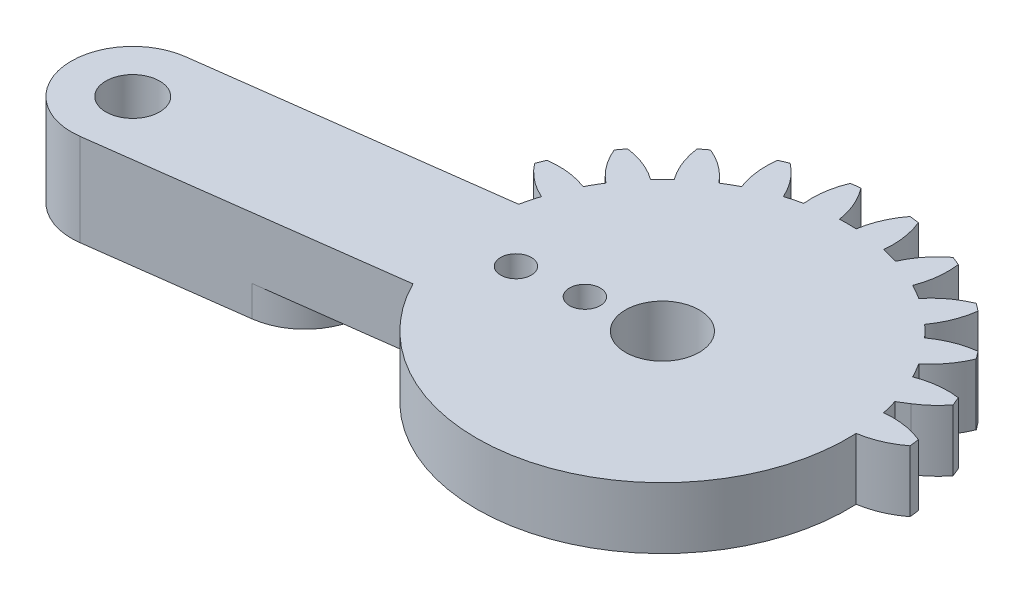
from build123d import *

# Parameters (mm, degrees)
SKETCH1_R           = 1.5
BOSS_EXTRUDE1_DEPTH = 4
SKETCH3_R           = 1.75
BOSS_EXTRUDE2_DEPTH = 4
CUT_EXTRUDE1_DEPTH  = 4
CUT_EXTRUDE2_REACH  = 6
SKETCH5_R           = 2.4
SKETCH5_R_2         = 1
SKETCH8_R           = 1.75
BOSS_EXTRUDE3_DEPTH = 2


with BuildPart() as part:
    # Sketch1 → Boss-Extrude1 (new body)
    with BuildSketch(Plane(origin=(0, 0, 0), x_dir=(1, 0, 0), z_dir=(0, 1, 0))):
        with BuildLine():
            Line((20.643657446, 4), (2.081641936, 4))
            ThreePointArc((2.081641936, 4), (2.861028333, 4.588201733), (3.521749436, 5.30713988))
            ThreePointArc((3.521749436, 5.30713988), (3.405395609, 5.596745198), (3.282888305, 5.883801663))
            ThreePointArc((3.282888305, 5.883801663), (1.93527598, 5.894040025), (0.627094961, 5.57027124))
            ThreePointArc((0.627094961, 5.57027124), (0.366286148, 6.046375), (0.084372603, 6.510293938))
            ThreePointArc((0.084372603, 6.510293938), (1.018855105, 7.48132754), (1.683794586, 8.65351323))
            ThreePointArc((1.683794586, 8.65351323), (1.496450048, 8.903135899), (1.303821399, 9.148703928))
            ThreePointArc((1.303821399, 9.148703928), (-0.000522033, 8.809805691), (-1.180330337, 8.158486898))
            ThreePointArc((-1.180330337, 8.158486898), (-1.555477026, 8.550865528), (-1.947855656, 8.926012217))
            ThreePointArc((-1.947855656, 8.926012217), (-1.296536862, 10.105820521), (-0.957638625, 11.410163953))
            ThreePointArc((-0.957638625, 11.410163953), (-1.203206655, 11.602792602), (-1.452829324, 11.79013714))
            ThreePointArc((-1.452829324, 11.79013714), (-2.625015014, 11.125197659), (-3.596048616, 10.190715157))
            ThreePointArc((-3.596048616, 10.190715157), (-4.059967554, 10.472628702), (-4.536071314, 10.733437515))
            ThreePointArc((-4.536071314, 10.733437515), (-4.212302529, 12.041618533), (-4.222540891, 13.389230859))
            ThreePointArc((-4.222540891, 13.389230859), (-4.509597355, 13.511738163), (-4.799202674, 13.62809199))
            ThreePointArc((-4.799202674, 13.62809199), (-5.759348103, 12.682425791), (-6.455432668, 11.528463019))
            ThreePointArc((-6.455432668, 11.528463019), (-6.976508546, 11.680699536), (-7.503891752, 11.809396783))
            ThreePointArc((-7.503891752, 11.809396783), (-7.529737283, 13.156800143), (-7.888414517, 14.455843809))
            ThreePointArc((-7.888414517, 14.455843809), (-8.197396993, 14.499881098), (-8.507248835, 14.537314892))
            ThreePointArc((-8.507248835, 14.537314892), (-9.18992168, 13.375367565), (-9.563620196, 12.080565177))
            ThreePointArc((-9.563620196, 12.080565177), (-10.106342554, 12.09275), (-10.649064912, 12.080565177))
            ThreePointArc((-10.649064912, 12.080565177), (-11.022763428, 13.375367565), (-11.705436272, 14.537314892))
            ThreePointArc((-11.705436272, 14.537314892), (-12.015288115, 14.499881098), (-12.324270591, 14.455843809))
            ThreePointArc((-12.324270591, 14.455843809), (-12.682947825, 13.156800143), (-12.708793355, 11.809396783))
            ThreePointArc((-12.708793355, 11.809396783), (-13.236176561, 11.680699536), (-13.757252439, 11.528463019))
            ThreePointArc((-13.757252439, 11.528463019), (-14.453337005, 12.682425791), (-15.413482434, 13.62809199))
            ThreePointArc((-15.413482434, 13.62809199), (-15.703087752, 13.511738163), (-15.990144217, 13.389230859))
            ThreePointArc((-15.990144217, 13.389230859), (-16.000382579, 12.041618533), (-15.676613793, 10.733437515))
            ThreePointArc((-15.676613793, 10.733437515), (-16.152717554, 10.472628702), (-16.616636492, 10.190715157))
            ThreePointArc((-16.616636492, 10.190715157), (-17.587670094, 11.125197659), (-18.759855783, 11.79013714))
            ThreePointArc((-18.759855783, 11.79013714), (-19.009478453, 11.602792602), (-19.255046482, 11.410163953))
            ThreePointArc((-19.255046482, 11.410163953), (-18.916148245, 10.105820521), (-18.264829452, 8.926012217))
            ThreePointArc((-18.264829452, 8.926012217), (-18.657208082, 8.550865528), (-19.032354771, 8.158486898))
            ThreePointArc((-19.032354771, 8.158486898), (-20.212163074, 8.809805691), (-21.516506507, 9.148703928))
            ThreePointArc((-21.516506507, 9.148703928), (-21.709135156, 8.903135899), (-21.896479694, 8.65351323))
            ThreePointArc((-21.896479694, 8.65351323), (-21.231540213, 7.48132754), (-20.297057711, 6.510293938))
            ThreePointArc((-20.297057711, 6.510293938), (-20.578971255, 6.046375), (-20.839780068, 5.57027124))
            ThreePointArc((-20.839780068, 5.57027124), (-22.147961087, 5.894040025), (-23.495573413, 5.883801663))
            ThreePointArc((-23.495573413, 5.883801663), (-23.618080717, 5.596745198), (-23.734434544, 5.30713988))
            ThreePointArc((-23.734434544, 5.30713988), (-22.788768345, 4.346994451), (-21.634805572, 3.650909885))
            ThreePointArc((-21.634805572, 3.650909885), (-21.78704209, 3.129834008), (-21.915739337, 2.602450802))
            ThreePointArc((-21.915739337, 2.602450802), (-23.263142697, 2.576605271), (-24.562186363, 2.217928037))
            ThreePointArc((-24.562186363, 2.217928037), (-24.606223651, 1.908945561), (-24.643657446, 1.599093719))
            ThreePointArc((-24.643657446, 1.599093719), (-23.481710119, 0.916420874), (-22.186907731, 0.542722358))
            ThreePointArc((-22.186907731, 0.542722358), (-22.199092554, 0), (-22.186907731, -0.542722358))
            ThreePointArc((-22.186907731, -0.542722358), (-23.481710119, -0.916420874), (-24.643657446, -1.599093719))
            ThreePointArc((-24.643657446, -1.599093719), (-24.606223651, -1.908945561), (-24.562186363, -2.217928037))
            ThreePointArc((-24.562186363, -2.217928037), (-23.263142697, -2.576605271), (-21.915739337, -2.602450802))
            ThreePointArc((-21.915739337, -2.602450802), (-21.78704209, -3.129834008), (-21.634805572, -3.650909885))
            ThreePointArc((-21.634805572, -3.650909885), (-22.788768345, -4.346994451), (-23.734434544, -5.30713988))
            ThreePointArc((-23.734434544, -5.30713988), (-23.618080717, -5.596745198), (-23.495573413, -5.883801663))
            ThreePointArc((-23.495573413, -5.883801663), (-22.147961087, -5.894040025), (-20.839780068, -5.57027124))
            ThreePointArc((-20.839780068, -5.57027124), (-20.578971255, -6.046375), (-20.297057711, -6.510293938))
            ThreePointArc((-20.297057711, -6.510293938), (-21.231540213, -7.48132754), (-21.896479694, -8.65351323))
            ThreePointArc((-21.896479694, -8.65351323), (-21.709135156, -8.903135899), (-21.516506507, -9.148703928))
            ThreePointArc((-21.516506507, -9.148703928), (-20.212163074, -8.809805691), (-19.032354771, -8.158486898))
            ThreePointArc((-19.032354771, -8.158486898), (-18.657208082, -8.550865528), (-18.264829452, -8.926012217))
            ThreePointArc((-18.264829452, -8.926012217), (-18.916148245, -10.105820521), (-19.255046482, -11.410163953))
            ThreePointArc((-19.255046482, -11.410163953), (-19.009478453, -11.602792602), (-18.759855783, -11.79013714))
            ThreePointArc((-18.759855783, -11.79013714), (-17.587670094, -11.125197659), (-16.616636492, -10.190715157))
            ThreePointArc((-16.616636492, -10.190715157), (-16.152717554, -10.472628702), (-15.676613793, -10.733437515))
            ThreePointArc((-15.676613793, -10.733437515), (-16.000382579, -12.041618533), (-15.990144217, -13.389230859))
            ThreePointArc((-15.990144217, -13.389230859), (-15.703087752, -13.511738163), (-15.413482434, -13.62809199))
            ThreePointArc((-15.413482434, -13.62809199), (-14.453337005, -12.682425791), (-13.757252439, -11.528463019))
            ThreePointArc((-13.757252439, -11.528463019), (-13.236176561, -11.680699536), (-12.708793355, -11.809396783))
            ThreePointArc((-12.708793355, -11.809396783), (-12.682947825, -13.156800143), (-12.324270591, -14.455843809))
            ThreePointArc((-12.324270591, -14.455843809), (-12.015288115, -14.499881098), (-11.705436272, -14.537314892))
            ThreePointArc((-11.705436272, -14.537314892), (-11.022763428, -13.375367565), (-10.649064912, -12.080565177))
            ThreePointArc((-10.649064912, -12.080565177), (-10.106342554, -12.09275), (-9.563620196, -12.080565177))
            ThreePointArc((-9.563620196, -12.080565177), (-9.18992168, -13.375367565), (-8.507248835, -14.537314892))
            ThreePointArc((-8.507248835, -14.537314892), (-8.197396993, -14.499881098), (-7.888414517, -14.455843809))
            ThreePointArc((-7.888414517, -14.455843809), (-7.529737283, -13.156800143), (-7.503891752, -11.809396783))
            ThreePointArc((-7.503891752, -11.809396783), (-6.976508546, -11.680699536), (-6.455432668, -11.528463019))
            ThreePointArc((-6.455432668, -11.528463019), (-5.759348103, -12.682425791), (-4.799202674, -13.62809199))
            ThreePointArc((-4.799202674, -13.62809199), (-4.509597355, -13.511738163), (-4.222540891, -13.389230859))
            ThreePointArc((-4.222540891, -13.389230859), (-4.212302529, -12.041618533), (-4.536071314, -10.733437515))
            ThreePointArc((-4.536071314, -10.733437515), (-4.059967554, -10.472628702), (-3.596048616, -10.190715157))
            ThreePointArc((-3.596048616, -10.190715157), (-2.625015014, -11.125197659), (-1.452829324, -11.79013714))
            ThreePointArc((-1.452829324, -11.79013714), (-1.203206655, -11.602792602), (-0.957638625, -11.410163953))
            ThreePointArc((-0.957638625, -11.410163953), (-1.296536862, -10.105820521), (-1.947855656, -8.926012217))
            ThreePointArc((-1.947855656, -8.926012217), (-1.555477026, -8.550865528), (-1.180330337, -8.158486898))
            ThreePointArc((-1.180330337, -8.158486898), (-0.000522033, -8.809805691), (1.303821399, -9.148703928))
            ThreePointArc((1.303821399, -9.148703928), (1.496450048, -8.903135899), (1.683794586, -8.65351323))
            ThreePointArc((1.683794586, -8.65351323), (1.018855105, -7.48132754), (0.084372603, -6.510293938))
            ThreePointArc((0.084372603, -6.510293938), (0.366286148, -6.046375), (0.627094961, -5.57027124))
            ThreePointArc((0.627094961, -5.57027124), (1.93527598, -5.894040025), (3.282888305, -5.883801663))
            ThreePointArc((3.282888305, -5.883801663), (3.405395609, -5.596745198), (3.521749436, -5.30713988))
            ThreePointArc((3.521749436, -5.30713988), (2.861028333, -4.588201733), (2.081641936, -4))
            Line((2.081641936, -4), (20.643657446, -4))
            ThreePointArc((20.643657446, -4), (24.643657446, 0), (20.643657446, 4))
        make_face()
        with Locations((-10.106342554, 0)):
            Circle(SKETCH1_R, mode=Mode.SUBTRACT)
        with Locations((20.643657446, 0)):
            Circle(SKETCH1_R, mode=Mode.SUBTRACT)
    extrude(amount=BOSS_EXTRUDE1_DEPTH)

    # Sketch3 → Boss-Extrude2 (add)
    with BuildSketch(Plane(origin=(0, 4, 0), x_dir=(1, 0, 0), z_dir=(0, 1, 0))):
        with BuildLine():
            ThreePointArc((-9.584237785, -3.965779445), (-14.072121999, -0.522104769), (-10.628447323, 3.965779445))
            Line((-10.628447323, 3.965779445), (-41.11537681, -0.047900965))
            ThreePointArc((-41.11537681, -0.047900965), (-44.559051487, -4.53578518), (-40.071167272, -7.979459856))
            Line((-40.071167272, -7.979459856), (-9.584237785, -3.965779445))
        make_face()
        with Locations((-40.593272041, -4.013680411)):
            Circle(SKETCH3_R, mode=Mode.SUBTRACT)
    extrude(amount=-BOSS_EXTRUDE2_DEPTH)

    # Sketch4 → Cut-Extrude1 (cut)
    with BuildSketch(Plane(origin=(0, 4, 0), x_dir=(1, 0, 0), z_dir=(0, 1, 0))):
        with BuildLine():
            ThreePointArc((20.643657446, -4), (24.643657446, 0), (20.643657446, 4))
            Line((20.643657446, 4), (2.081641936, 4))
            Line((2.081641936, 4), (1.43808022, 3.600125745))
            ThreePointArc((1.43808022, 3.600125745), (1.581217534, 3.104116905), (1.70305423, 2.602450802))
            ThreePointArc((1.70305423, 2.602450802), (3.050457589, 2.576605271), (4.349501255, 2.217928037))
            ThreePointArc((4.349501255, 2.217928037), (4.393538544, 1.908945561), (4.430972339, 1.599093719))
            ThreePointArc((4.430972339, 1.599093719), (3.269025011, 0.916420874), (1.974222624, 0.542722358))
            ThreePointArc((1.974222624, 0.542722358), (1.70305423, -2.602450802), (0.627094961, -5.57027124))
            ThreePointArc((0.627094961, -5.57027124), (1.93527598, -5.894040025), (3.282888305, -5.883801663))
            ThreePointArc((3.282888305, -5.883801663), (3.405395609, -5.596745198), (3.521749436, -5.30713988))
            ThreePointArc((3.521749436, -5.30713988), (2.861028333, -4.588201733), (2.081641936, -4))
            Line((2.081641936, -4), (20.643657446, -4))
        make_face()
        with BuildLine():
            ThreePointArc((1.683794586, -8.65351323), (1.018855105, -7.48132754), (0.084372603, -6.510293938))
            ThreePointArc((0.084372603, -6.510293938), (-0.512518948, -7.361599771), (-1.180330337, -8.158486898))
            ThreePointArc((-1.180330337, -8.158486898), (-0.000522033, -8.809805691), (1.303821399, -9.148703928))
            ThreePointArc((1.303821399, -9.148703928), (1.496450048, -8.903135899), (1.683794586, -8.65351323))
        make_face()
        with BuildLine():
            ThreePointArc((-0.957638625, -11.410163953), (-1.296536862, -10.105820521), (-1.947855656, -8.926012217))
            ThreePointArc((-1.947855656, -8.926012217), (-2.744742783, -9.593823606), (-3.596048616, -10.190715157))
            ThreePointArc((-3.596048616, -10.190715157), (-2.625015014, -11.125197659), (-1.452829324, -11.79013714))
            ThreePointArc((-1.452829324, -11.79013714), (-1.203206655, -11.602792602), (-0.957638625, -11.410163953))
        make_face()
        with BuildLine():
            ThreePointArc((-4.222540891, -13.389230859), (-4.212302529, -12.041618533), (-4.536071314, -10.733437515))
            ThreePointArc((-4.536071314, -10.733437515), (-5.478647477, -11.172244217), (-6.455432668, -11.528463019))
            ThreePointArc((-6.455432668, -11.528463019), (-5.759348103, -12.682425791), (-4.799202674, -13.62809199))
            ThreePointArc((-4.799202674, -13.62809199), (-4.509597355, -13.511738163), (-4.222540891, -13.389230859))
        make_face()
        with BuildLine():
            ThreePointArc((-7.888414517, -14.455843809), (-7.529737283, -13.156800143), (-7.503891752, -11.809396783))
            ThreePointArc((-7.503891752, -11.809396783), (-8.527921943, -11.989294847), (-9.563620196, -12.080565177))
            ThreePointArc((-9.563620196, -12.080565177), (-9.18992168, -13.375367565), (-8.507248835, -14.537314892))
            ThreePointArc((-8.507248835, -14.537314892), (-8.197396993, -14.499881098), (-7.888414517, -14.455843809))
        make_face()
        with BuildLine():
            ThreePointArc((-11.705436272, -14.537314892), (-11.022763428, -13.375367565), (-10.649064912, -12.080565177))
            ThreePointArc((-10.649064912, -12.080565177), (-11.684763165, -11.989294847), (-12.708793355, -11.809396783))
            ThreePointArc((-12.708793355, -11.809396783), (-12.682947825, -13.156800143), (-12.324270591, -14.455843809))
            ThreePointArc((-12.324270591, -14.455843809), (-12.015288115, -14.499881098), (-11.705436272, -14.537314892))
        make_face()
        with BuildLine():
            ThreePointArc((-15.413482434, -13.62809199), (-14.453337005, -12.682425791), (-13.757252439, -11.528463019))
            ThreePointArc((-13.757252439, -11.528463019), (-14.734037631, -11.172244217), (-15.676613793, -10.733437515))
            ThreePointArc((-15.676613793, -10.733437515), (-16.000382579, -12.041618533), (-15.990144217, -13.389230859))
            ThreePointArc((-15.990144217, -13.389230859), (-15.703087752, -13.511738163), (-15.413482434, -13.62809199))
        make_face()
        with BuildLine():
            ThreePointArc((-18.759855783, -11.79013714), (-17.587670094, -11.125197659), (-16.616636492, -10.190715157))
            ThreePointArc((-16.616636492, -10.190715157), (-17.467942324, -9.593823606), (-18.264829452, -8.926012217))
            ThreePointArc((-18.264829452, -8.926012217), (-18.916148245, -10.105820521), (-19.255046482, -11.410163953))
            ThreePointArc((-19.255046482, -11.410163953), (-19.009478453, -11.602792602), (-18.759855783, -11.79013714))
        make_face()
        with BuildLine():
            ThreePointArc((-21.516506507, -9.148703928), (-20.212163074, -8.809805691), (-19.032354771, -8.158486898))
            ThreePointArc((-19.032354771, -8.158486898), (-19.70016616, -7.361599771), (-20.297057711, -6.510293938))
            ThreePointArc((-20.297057711, -6.510293938), (-21.231540213, -7.48132754), (-21.896479694, -8.65351323))
            ThreePointArc((-21.896479694, -8.65351323), (-21.709135156, -8.903135899), (-21.516506507, -9.148703928))
        make_face()
        with BuildLine():
            ThreePointArc((-21.942853375, 2.47620963), (-21.92946485, 2.539366405), (-21.915739337, 2.602450802))
            ThreePointArc((-21.915739337, 2.602450802), (-23.263142697, 2.576605271), (-24.562186363, 2.217928037))
            ThreePointArc((-24.562186363, 2.217928037), (-24.56889027, 2.173784387), (-24.575459377, 2.129620475))
            Line((-24.575459377, 2.129620475), (-21.942853375, 2.47620963))
        make_face()
        with BuildLine():
            ThreePointArc((-23.495573413, -5.883801663), (-22.147961087, -5.894040025), (-20.839780068, -5.57027124))
            ThreePointArc((-20.839780068, -5.57027124), (-20.869365339, -5.512888815), (-20.898643838, -5.455349261))
            Line((-20.898643838, -5.455349261), (-23.531249839, -5.801938416))
            ThreePointArc((-23.531249839, -5.801938416), (-23.513474108, -5.842897269), (-23.495573413, -5.883801663))
        make_face()
    extrude(amount=-CUT_EXTRUDE1_DEPTH, mode=Mode.SUBTRACT)

    # Sketch5 → Cut-Extrude2 (cut, up to next)
    with BuildSketch(Plane(origin=(0, 4, 0), x_dir=(1, 0, 0), z_dir=(0, 1, 0)), mode=Mode.PRIVATE) as cut_extrude2_sk1:
        with Locations((-10.106342554, 0)):
            Circle(SKETCH5_R)
    cut_extrude2_tool1 = extrude(cut_extrude2_sk1.sketch, amount=-CUT_EXTRUDE2_REACH, mode=Mode.PRIVATE) & part.part
    add(cut_extrude2_tool1.solids().sort_by_distance((-10.106343, 4, 0))[0], mode=Mode.SUBTRACT)
    # Sketch5 → Cut-Extrude2 (cut, up to next)
    with BuildSketch(Plane(origin=(0, 4, 0), x_dir=(1, 0, 0), z_dir=(0, 1, 0)), mode=Mode.PRIVATE) as cut_extrude2_sk2:
        with Locations((-14.56784443, -0.587367865)):
            Circle(SKETCH5_R_2)
    cut_extrude2_tool2 = extrude(cut_extrude2_sk2.sketch, amount=-CUT_EXTRUDE2_REACH, mode=Mode.PRIVATE) & part.part
    add(cut_extrude2_tool2.solids().sort_by_distance((-14.567844, 4, 0.587368))[0], mode=Mode.SUBTRACT)
    # Sketch5 → Cut-Extrude2 (cut, up to next)
    with BuildSketch(Plane(origin=(0, 4, 0), x_dir=(1, 0, 0), z_dir=(0, 1, 0)), mode=Mode.PRIVATE) as cut_extrude2_sk3:
        with Locations((-18.533623876, -1.109472634)):
            Circle(SKETCH5_R_2)
    cut_extrude2_tool3 = extrude(cut_extrude2_sk3.sketch, amount=-CUT_EXTRUDE2_REACH, mode=Mode.PRIVATE) & part.part
    add(cut_extrude2_tool3.solids().sort_by_distance((-18.533624, 4, 1.109473))[0], mode=Mode.SUBTRACT)

    # Sketch8 → Boss-Extrude3 (add)
    with BuildSketch(Plane.XZ):
        with BuildLine():
            Line((-30.156718658, 6.674197934), (-40.071167272, 7.979459856))
            ThreePointArc((-40.071167272, 7.979459856), (-44.559051487, 4.53578518), (-41.11537681, 0.047900965))
            Line((-41.11537681, 0.047900965), (-31.200928196, -1.257360957))
            ThreePointArc((-31.200928196, -1.257360957), (-26.713043982, 2.18631372), (-30.156718658, 6.674197934))
        make_face()
        with Locations((-40.593272041, 4.013680411)):
            Circle(SKETCH8_R, mode=Mode.SUBTRACT)
    extrude(amount=BOSS_EXTRUDE3_DEPTH)


solid = part.part
